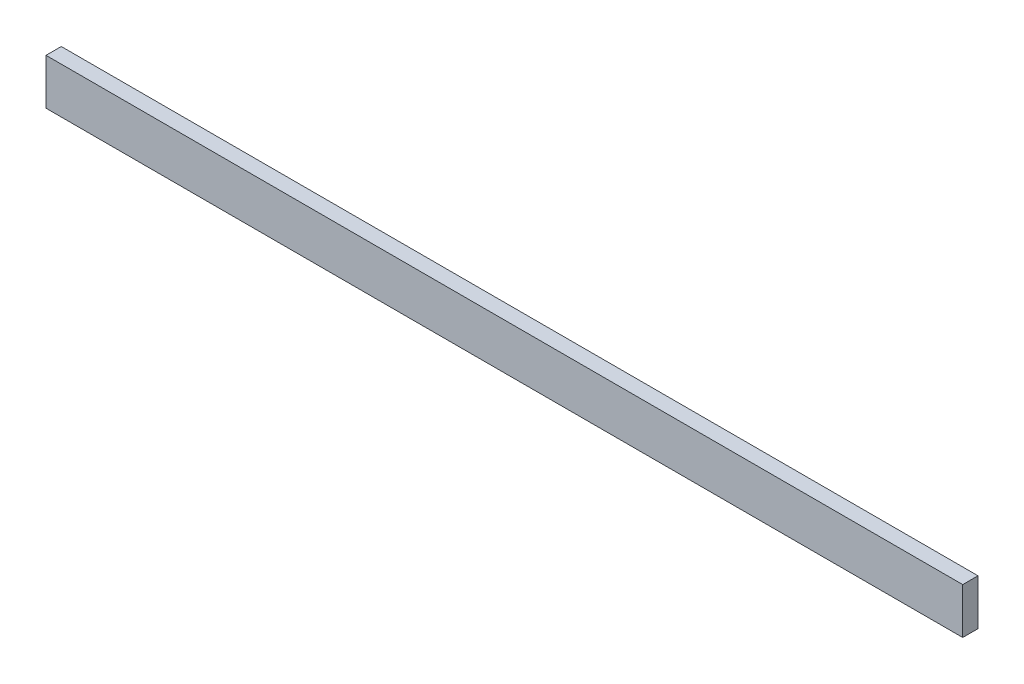
from build123d import *

# Parameters (mm, degrees)
SKETCH1_W           = 762
SKETCH1_H           = 38.1
BOSS_EXTRUDE1_DEPTH = 12.7


with BuildPart() as part:
    # Sketch1 → Boss-Extrude1 (new body)
    with BuildSketch(Plane.XY):
        with Locations((314.390660814, 43.949953446)):
            Rectangle(SKETCH1_W, SKETCH1_H)
    extrude(amount=BOSS_EXTRUDE1_DEPTH)


solid = part.part
